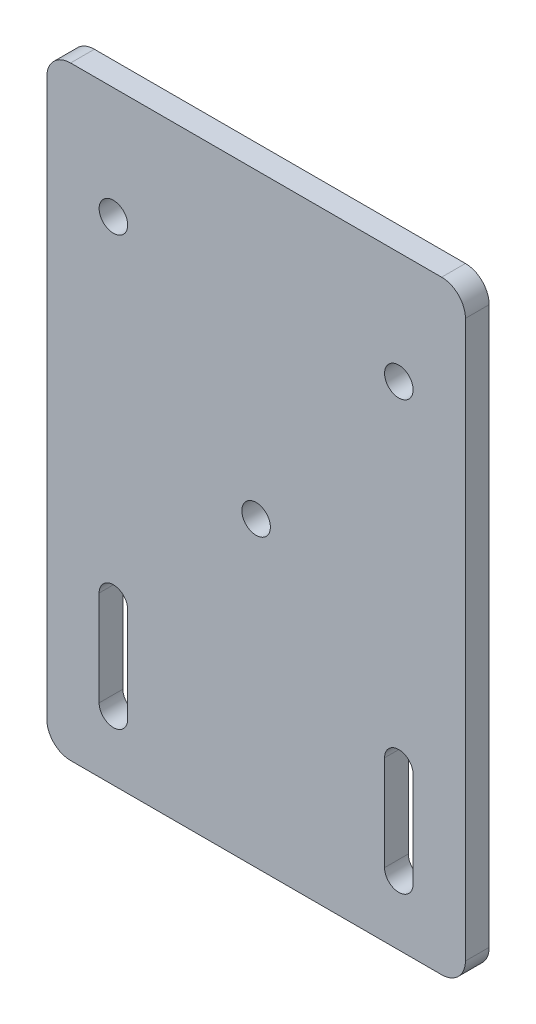
from build123d import *

# Parameters (mm, degrees)
SKETCH1_R           = 3
BOSS_EXTRUDE1_DEPTH = 5


with BuildPart() as part:
    # Sketch1 → Boss-Extrude1 (new body)
    with BuildSketch(Plane.XY):
        with BuildLine():
            Line((-39, -63.5), (39, -63.5))
            ThreePointArc((39, -63.5), (42.535533906, -62.035533906), (44, -58.5))
            Line((44, -58.5), (44, 58.5))
            ThreePointArc((44, 58.5), (42.535533906, 62.035533906), (39, 63.5))
            Line((39, 63.5), (-39, 63.5))
            ThreePointArc((-39, 63.5), (-42.535533906, 62.035533906), (-44, 58.5))
            Line((-44, 58.5), (-44, -58.5))
            ThreePointArc((-44, -58.5), (-42.535533906, -62.035533906), (-39, -63.5))
        make_face()
        with Locations((-30, 40)):
            Circle(SKETCH1_R, mode=Mode.SUBTRACT)
        with Locations((30, 40)):
            Circle(SKETCH1_R, mode=Mode.SUBTRACT)
        Circle(SKETCH1_R, mode=Mode.SUBTRACT)
        with BuildLine():
            Line((27, -30), (27, -50))
            ThreePointArc((27, -50), (30, -53), (33, -50))
            Line((33, -50), (33, -30))
            ThreePointArc((33, -30), (30, -27), (27, -30))
        make_face(mode=Mode.SUBTRACT)
        with BuildLine():
            Line((-33, -30), (-33, -50))
            ThreePointArc((-33, -50), (-30, -53), (-27, -50))
            Line((-27, -50), (-27, -30))
            ThreePointArc((-27, -30), (-30, -27), (-33, -30))
        make_face(mode=Mode.SUBTRACT)
    extrude(amount=BOSS_EXTRUDE1_DEPTH)


solid = part.part
